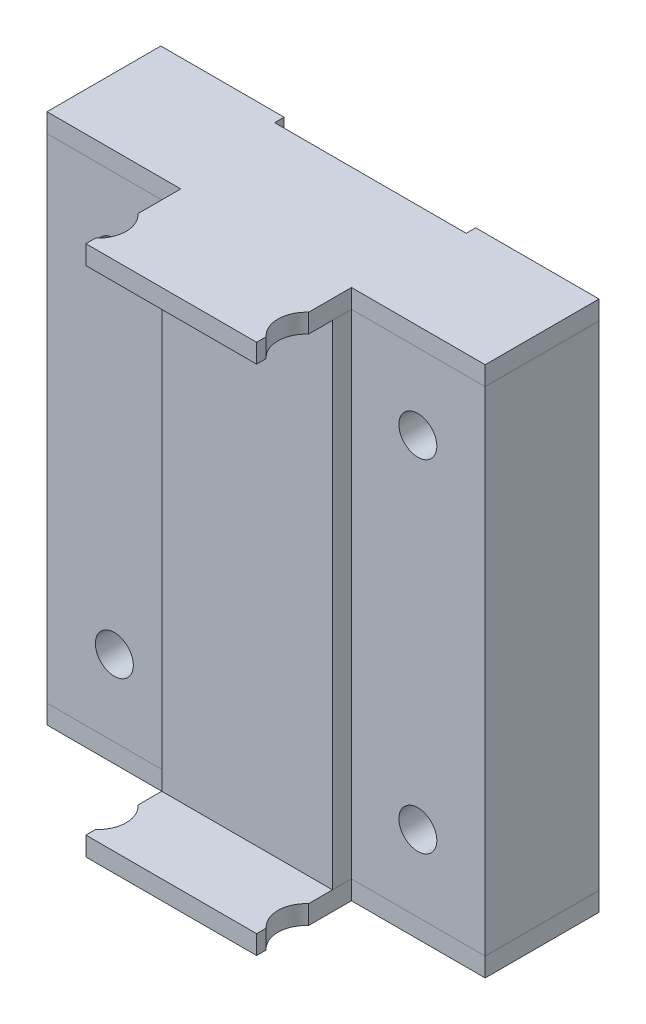
from build123d import *

# Parameters (mm, degrees)
BOSS_EXTRUDE1_DEPTH = 26
CUT_EXTRUDE1_REACH  = 16
SKETCH2_R           = 2
BOSS_EXTRUDE2_DEPTH = 2


with BuildPart() as part:
    # Sketch1 → Boss-Extrude1 (new body, symmetric)
    with BuildSketch(Plane(origin=(0, 0, 0), x_dir=(1, 0, 0), z_dir=(0, 1, 0))):
        Polygon((23.1, 0), (9, 0), (9, -2), (-9, -2), (-9, 0), (-23.1, 0), (-23.1, 12), (-10.1, 12), (-10.1, 11), (10.1, 11), (10.1, 12), (23.1, 12), align=None)
    extrude(amount=BOSS_EXTRUDE1_DEPTH, both=True)

    # Sketch2 → Cut-Extrude1 (cut, up to next)
    with BuildSketch(Plane(origin=(0, 0, -12), x_dir=(-1, 0, 0), z_dir=(0, 0, -1)), mode=Mode.PRIVATE) as cut_extrude1_sk1:
        with Locations((16, -18)):
            Circle(SKETCH2_R)
    cut_extrude1_tool1 = extrude(cut_extrude1_sk1.sketch, amount=-CUT_EXTRUDE1_REACH, mode=Mode.PRIVATE) & part.part
    add(cut_extrude1_tool1.solids().sort_by_distance((-16, -18, -12))[0], mode=Mode.SUBTRACT)
    # Sketch2 → Cut-Extrude1 (cut, up to next)
    with BuildSketch(Plane(origin=(0, 0, -12), x_dir=(-1, 0, 0), z_dir=(0, 0, -1)), mode=Mode.PRIVATE) as cut_extrude1_sk2:
        with Locations((-16, -18)):
            Circle(SKETCH2_R)
    cut_extrude1_tool2 = extrude(cut_extrude1_sk2.sketch, amount=-CUT_EXTRUDE1_REACH, mode=Mode.PRIVATE) & part.part
    add(cut_extrude1_tool2.solids().sort_by_distance((16, -18, -12))[0], mode=Mode.SUBTRACT)
    # Sketch2 → Cut-Extrude1 (cut, up to next)
    with BuildSketch(Plane(origin=(0, 0, -12), x_dir=(-1, 0, 0), z_dir=(0, 0, -1)), mode=Mode.PRIVATE) as cut_extrude1_sk3:
        with Locations((-16, 18)):
            Circle(SKETCH2_R)
    cut_extrude1_tool3 = extrude(cut_extrude1_sk3.sketch, amount=-CUT_EXTRUDE1_REACH, mode=Mode.PRIVATE) & part.part
    add(cut_extrude1_tool3.solids().sort_by_distance((16, 18, -12))[0], mode=Mode.SUBTRACT)
    # Sketch2 → Cut-Extrude1 (cut, up to next)
    with BuildSketch(Plane(origin=(0, 0, -12), x_dir=(-1, 0, 0), z_dir=(0, 0, -1)), mode=Mode.PRIVATE) as cut_extrude1_sk4:
        with Locations((16, 18)):
            Circle(SKETCH2_R)
    cut_extrude1_tool4 = extrude(cut_extrude1_sk4.sketch, amount=-CUT_EXTRUDE1_REACH, mode=Mode.PRIVATE) & part.part
    add(cut_extrude1_tool4.solids().sort_by_distance((-16, 18, -12))[0], mode=Mode.SUBTRACT)


with BuildPart() as body_2:
    # Sketch3 → Boss-Extrude2 (new body)
    with BuildSketch(Plane(origin=(0, 26, 0), x_dir=(1, 0, 0), z_dir=(0, 1, 0))):
        with BuildLine():
            Line((10.1, 11), (-10.1, 11))
            Line((-10.1, 11), (-10.1, 12))
            Line((-10.1, 12), (-23.1, 12))
            Line((-23.1, 12), (-23.1, 0))
            Line((-23.1, 0), (-9, 0))
            Line((-9, 0), (-9, -4.513932023))
            ThreePointArc((-9, -4.513932023), (-8, -6.75), (-9, -8.986067977))
            Line((-9, -8.986067977), (-9, -10))
            Line((-9, -10), (9, -10))
            Line((9, -10), (9, -8.986067977))
            ThreePointArc((9, -8.986067977), (8, -6.75), (9, -4.513932023))
            Line((9, -4.513932023), (9, 0))
            Line((9, 0), (23.1, 0))
            Line((23.1, 0), (23.1, 12))
            Line((23.1, 12), (10.1, 12))
            Line((10.1, 12), (10.1, 11))
        make_face()
    extrude(amount=BOSS_EXTRUDE2_DEPTH)


with BuildPart() as body_3:
    # Mirror2: mirrored copy
    add(body_2.part.mirror(Plane.ZX))


solid = Compound([part.part, body_2.part, body_3.part])
